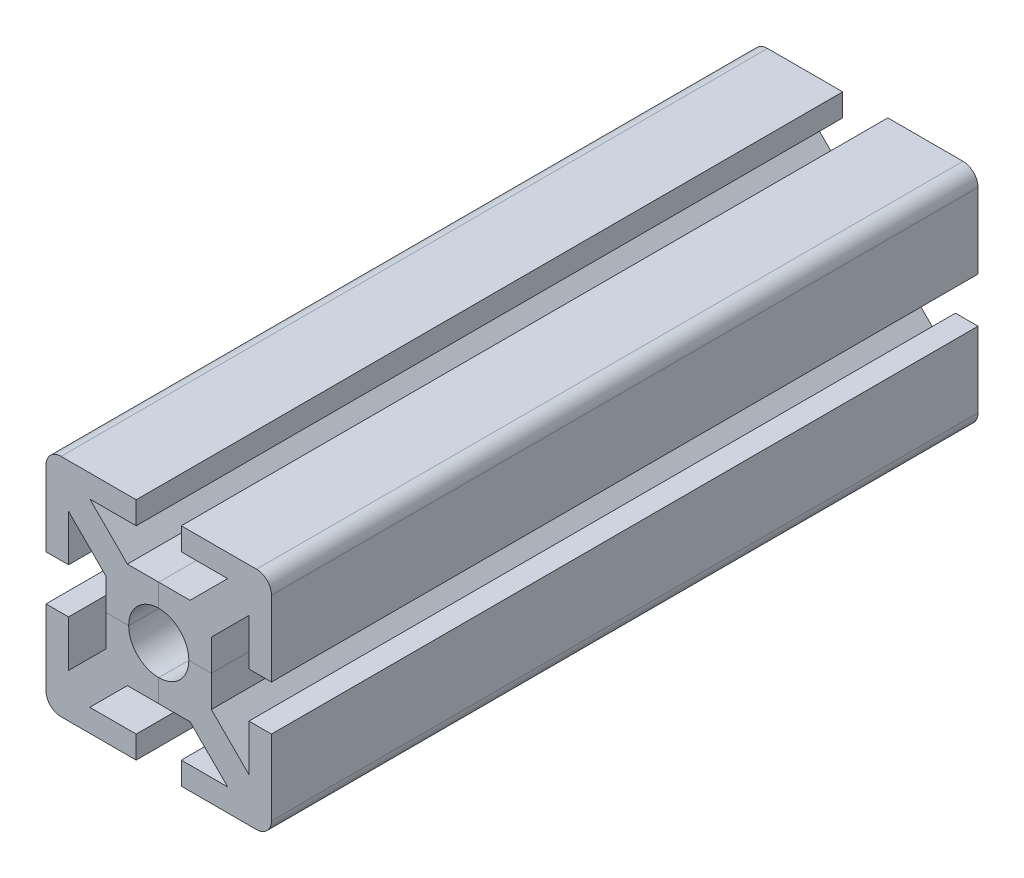
from build123d import *

# Parameters (mm, degrees)
SALIENTE_EXTRUIR1_DEPTH = 47
REDONDEO1_R             = 2
MATRIZC4_COUNT          = 4


with BuildPart() as part:
    # Croquis1 → Saliente-Extruir1 (new body, symmetric)
    with BuildSketch(Plane.XY):
        with BuildLine():
            Line((0, 4), (0, 7))
            Line((0, 7), (4.171572875, 7))
            Line((4.171572875, 7), (9.171572875, 12))
            Line((9.171572875, 12), (3, 12))
            Line((3, 12), (3, 15))
            Line((3, 15), (15, 15))
            Line((15, 15), (2.828427125, 2.828427125))
            ThreePointArc((2.828427125, 2.828427125), (1.530733729, 3.69551813), (0, 4))
        make_face()
    saliente_extruir1 = extrude(amount=SALIENTE_EXTRUIR1_DEPTH, both=True)

    # Simetría1: Saliente-Extruir1 across plane
    add(saliente_extruir1.mirror(Plane(origin=(2.828427125, 2.828427125, 47), x_dir=(0, 0, 1), z_dir=(-0.707106781, 0.707106781, 0))))

    # Redondeo1
    redondeo1_edges = [part.edges().sort_by_distance(p)[0] for p in [
        (15, 15, 0),
    ]]
    fillet(redondeo1_edges, radius=REDONDEO1_R)


with BuildPart() as matrizc4_1:
    # MatrizC4: pattern copy
    add(part.part.rotate(Axis((0, 0, 0), (0, 0, 1)), 1 * 360 / MATRIZC4_COUNT))


with BuildPart() as matrizc4_2:
    # MatrizC4: pattern copy
    add(part.part.rotate(Axis((0, 0, 0), (0, 0, 1)), 2 * 360 / MATRIZC4_COUNT))


with BuildPart() as matrizc4_3:
    # MatrizC4: pattern copy
    add(part.part.rotate(Axis((0, 0, 0), (0, 0, 1)), 3 * 360 / MATRIZC4_COUNT))


solid = Compound([part.part, matrizc4_1.part, matrizc4_2.part, matrizc4_3.part])
